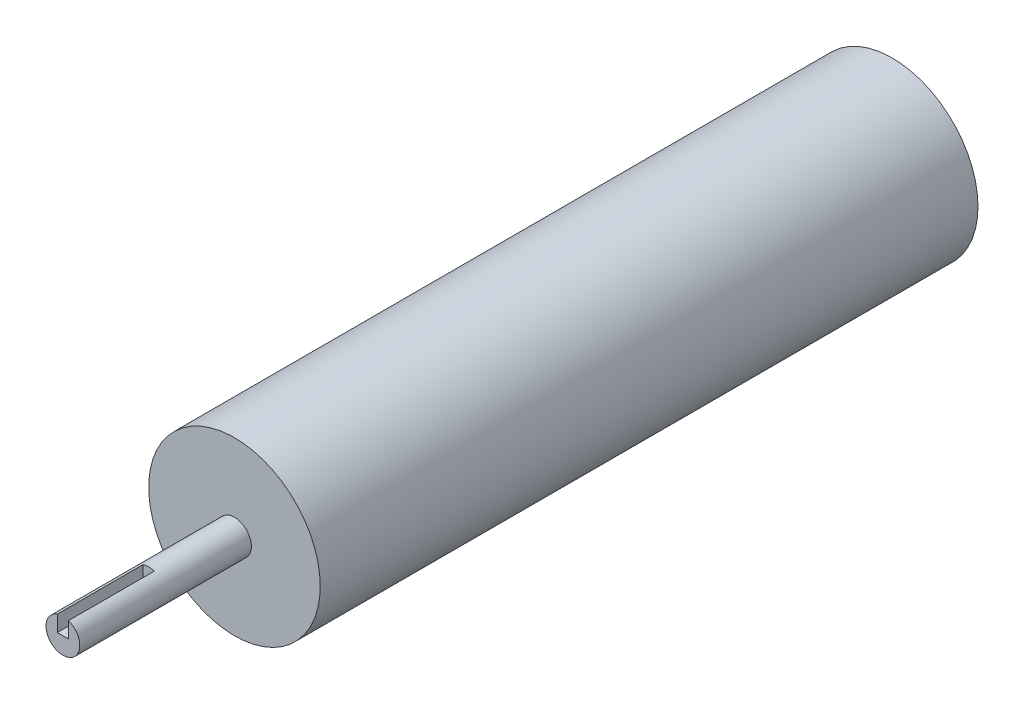
from build123d import *

# Parameters (mm, degrees)
SKETCH1_R               = 38.1
BOSS_EXTRUDE1_DEPTH     = 292.1
SKETCH3_R               = 7.5
BOSS_EXTRUDE2_DEPTH     = 76.2
CUT_EXTRUDE1_DEPTH      = 1
CUT_EXTRUDE1_DEPTH_BACK = 38.1
SKETCH5_R               = 7.5
BOSS_EXTRUDE3_DEPTH     = 11


with BuildPart() as part:
    # Sketch1 → Boss-Extrude1 (new body)
    with BuildSketch(Plane.XY):
        Circle(SKETCH1_R)
    extrude(amount=BOSS_EXTRUDE1_DEPTH)

    # Sketch3 → Boss-Extrude2 (add)
    with BuildSketch(Plane.XY.offset(292.1)):
        Circle(SKETCH3_R)
    extrude(amount=BOSS_EXTRUDE2_DEPTH)

    # Sketch4 → Cut-Extrude1 (cut, two sides)
    with BuildSketch(Plane.XY.offset(368.3)) as cut_extrude1_sk:
        Polygon((-2.5, 138.541811076), (-2.5, 7.071067812), (-2.5, 0), (2.5, 0), (2.5, 7.071067812), (2.5, 138.541811076), (2.5, 401.483297603), (-2.5, 401.483297603), align=None)
    extrude(amount=CUT_EXTRUDE1_DEPTH, mode=Mode.SUBTRACT)
    extrude(cut_extrude1_sk.sketch, amount=-CUT_EXTRUDE1_DEPTH_BACK, mode=Mode.SUBTRACT)

    # Sketch5 → Boss-Extrude3 (add)
    with BuildSketch(Plane(origin=(0, 0, 0), x_dir=(-1, 0, 0), z_dir=(0, 0, -1))):
        Circle(SKETCH5_R)
    extrude(amount=BOSS_EXTRUDE3_DEPTH)


solid = part.part
